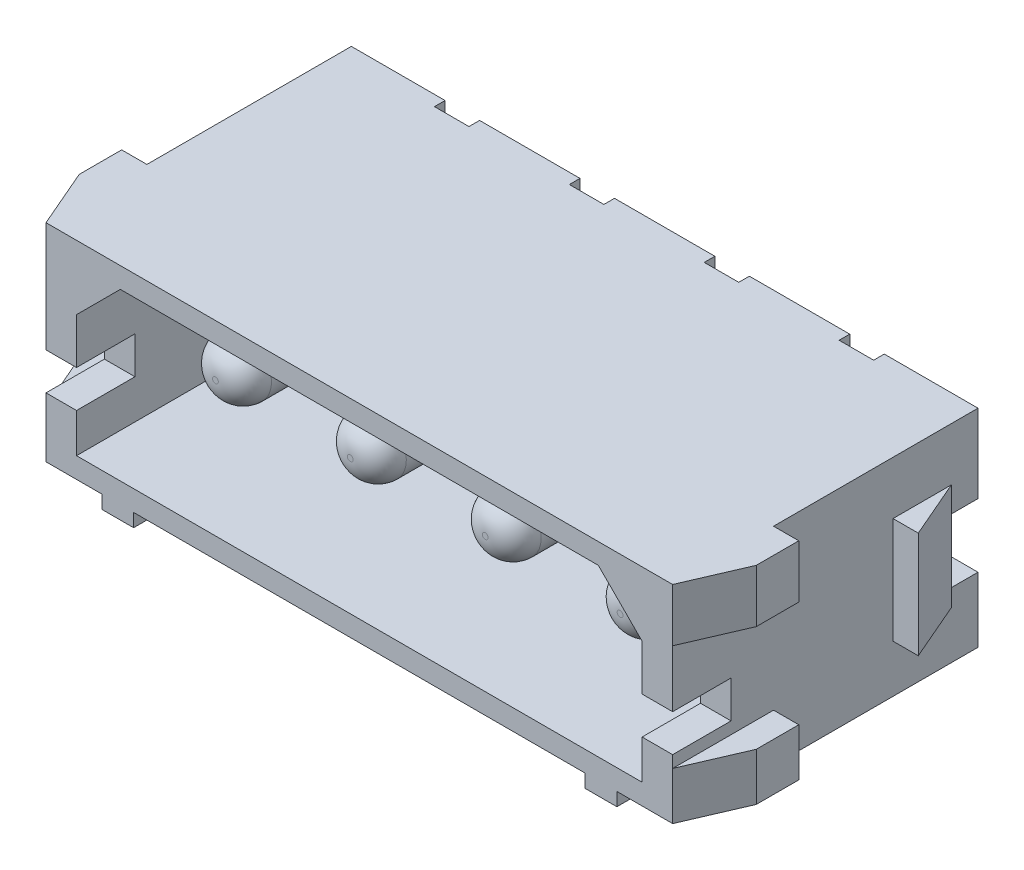
from build123d import *

# Parameters (mm, degrees)
BOSS_EXTRUDE1_DEPTH = 4.15
SKETCH2_W           = 10
SKETCH2_H           = 5
SKETCH2_W_2         = 17
CUT_EXTRUDE1_DEPTH  = 12.5
SKETCH3_W           = 5
SKETCH3_H           = 4
CUT_EXTRUDE2_DEPTH  = 6.3
SKETCH4_W           = 5
SKETCH4_H           = 4.540427611
SKETCH4_H_2         = 5
CUT_EXTRUDE3_DEPTH  = 6.3
CUT_EXTRUDE4_DEPTH  = 7.3
SKETCH6_R           = 1.11
BOSS_EXTRUDE2_DEPTH = 5.1
FILLET1_R           = 1
SKETCH7_W           = 5
SKETCH7_H           = 1.4
CUT_EXTRUDE5_DEPTH  = 25.55
SKETCH8_W           = 1.3
SKETCH8_H           = 3
CUT_EXTRUDE6_DEPTH  = 9.3
SKETCH9_W           = 3
SKETCH9_H           = 2.4
CUT_EXTRUDE7_DEPTH  = 25.55
SKETCH10_W          = 1.3
SKETCH10_H          = 0.4
BOSS_EXTRUDE3_DEPTH = 6.5
SKETCH11_W          = 20
SKETCH11_H          = 5
CUT_EXTRUDE8_DEPTH  = 12.5


with BuildPart() as part:
    # Sketch1 → Boss-Extrude1 (new body, symmetric)
    with BuildSketch(Plane(origin=(0, 0, 0), x_dir=(1, 0, 0), z_dir=(0, 1, 0))):
        Polygon((-11.8, 0), (11.8, 0), (11.8, -1), (12.75, -3.2), (11.8, -3.2), (11.8, -7.7), (12.75, -7.7), (12.75, -9.3), (11.8, -11.5), (-11.8, -11.5), (-12.75, -9.3), (-12.75, -7.7), (-11.8, -7.7), (-11.8, -3.2), (-12.75, -3.2), (-11.8, -1), align=None)
    extrude(amount=BOSS_EXTRUDE1_DEPTH, both=True)

    # Sketch2 → Cut-Extrude1 (cut, through all)
    with BuildSketch(Plane.XY.offset(11.5)):
        with Locations((14.7, -6.15)):
            Rectangle(SKETCH2_W, SKETCH2_H)
        with Locations((-14.7, -6.15)):
            Rectangle(SKETCH2_W, SKETCH2_H)
        with Locations((0, -6.15)):
            Rectangle(SKETCH2_W_2, SKETCH2_H)
    extrude(amount=-CUT_EXTRUDE1_DEPTH, mode=Mode.SUBTRACT)

    # Sketch3 → Cut-Extrude2 (cut)
    with BuildSketch(Plane.XY.offset(11.5)):
        with Locations((14.3, 0.15)):
            Rectangle(SKETCH3_W, SKETCH3_H)
        with Locations((-14.3, 0.15)):
            Rectangle(SKETCH3_W, SKETCH3_H)
    extrude(amount=-CUT_EXTRUDE2_DEPTH, mode=Mode.SUBTRACT)

    # Sketch4 → Cut-Extrude3 (cut)
    with BuildSketch(Plane(origin=(0, 0, 0), x_dir=(-1, 0, 0), z_dir=(0, 0, -1))):
        with Locations((14.3, 4.420213806)):
            Rectangle(SKETCH4_W, SKETCH4_H)
        with Locations((14.3, -4.35)):
            Rectangle(SKETCH4_W, SKETCH4_H_2)
        with Locations((-14.3, -4.35)):
            Rectangle(SKETCH4_W, SKETCH4_H_2)
        with Locations((-14.3, 4.65)):
            Rectangle(SKETCH4_W, SKETCH4_H_2)
    extrude(amount=-CUT_EXTRUDE3_DEPTH, mode=Mode.SUBTRACT)

    # Sketch5 → Cut-Extrude4 (cut)
    with BuildSketch(Plane.XY.offset(11.5)):
        Polygon((-10.65, -2.875), (10.65, -2.875), (10.65, 1.725), (9, 3.375), (-9, 3.375), (-10.65, 1.725), align=None)
    extrude(amount=-CUT_EXTRUDE4_DEPTH, mode=Mode.SUBTRACT)

    # Sketch6 → Boss-Extrude2 (add)
    with BuildSketch(Plane.XY.offset(4.2)):
        with Locations((-7.62, 0)):
            Circle(SKETCH6_R)
        with Locations((-2.54, 0)):
            Circle(SKETCH6_R)
        with Locations((2.54, -3.41e-07)):
            Circle(SKETCH6_R)
        with Locations((7.62, 0)):
            Circle(SKETCH6_R)
    extrude(amount=BOSS_EXTRUDE2_DEPTH)

    # Fillet1
    fillet1_edges = [part.edges().sort_by_distance(p)[0] for p in [
        (-8.73, 0, 9.3),
        (-3.65, 0, 9.3),
        (1.43, -3.41e-07, 9.3),
        (6.51, 0, 9.3),
    ]]
    fillet(fillet1_edges, radius=FILLET1_R)

    # Sketch7 → Cut-Extrude5 (cut, through all)
    with BuildSketch(Plane(origin=(11.8, 0, 0), x_dir=(0, 0, -1), z_dir=(1, 0, 0))):
        with Locations((-11.8, -0.7)):
            Rectangle(SKETCH7_W, SKETCH7_H)
    extrude(amount=-CUT_EXTRUDE5_DEPTH, mode=Mode.SUBTRACT)

    # Sketch8 → Cut-Extrude6 (cut, through all)
    with BuildSketch(Plane(origin=(0, 4.15, 0), x_dir=(1, 0, 0), z_dir=(0, 1, 0))):
        with Locations((-7.62, 1.1)):
            Rectangle(SKETCH8_W, SKETCH8_H)
        with Locations((-2.54, 1.1)):
            Rectangle(SKETCH8_W, SKETCH8_H)
        with Locations((2.54, 1.1)):
            Rectangle(SKETCH8_W, SKETCH8_H)
        with Locations((7.62, 1.1)):
            Rectangle(SKETCH8_W, SKETCH8_H)
    extrude(amount=-CUT_EXTRUDE6_DEPTH, mode=Mode.SUBTRACT)

    # Sketch9 → Cut-Extrude7 (cut, through all)
    with BuildSketch(Plane(origin=(11.8, 0, 0), x_dir=(0, 0, -1), z_dir=(1, 0, 0))):
        with Locations((0.5, 0)):
            Rectangle(SKETCH9_W, SKETCH9_H)
    extrude(amount=-CUT_EXTRUDE7_DEPTH, mode=Mode.SUBTRACT)

    # Sketch10 → Boss-Extrude3 (add)
    with BuildSketch(Plane(origin=(0, -1.2, 0), x_dir=(1, 0, 0), z_dir=(0, 1, 0))):
        with Locations((-7.62, -0.2)):
            Rectangle(SKETCH10_W, SKETCH10_H)
        with Locations((-2.54, -0.2)):
            Rectangle(SKETCH10_W, SKETCH10_H)
        with Locations((2.54, -0.2)):
            Rectangle(SKETCH10_W, SKETCH10_H)
        with Locations((7.62, -0.2)):
            Rectangle(SKETCH10_W, SKETCH10_H)
    extrude(amount=-BOSS_EXTRUDE3_DEPTH)

    # Sketch11 → Cut-Extrude8 (cut, through all)
    with BuildSketch(Plane(origin=(0, 0, 0), x_dir=(-1, 0, 0), z_dir=(0, 0, -1))):
        with Locations((0, -7.45)):
            Rectangle(SKETCH11_W, SKETCH11_H)
    extrude(amount=-CUT_EXTRUDE8_DEPTH, mode=Mode.SUBTRACT)


solid = part.part
